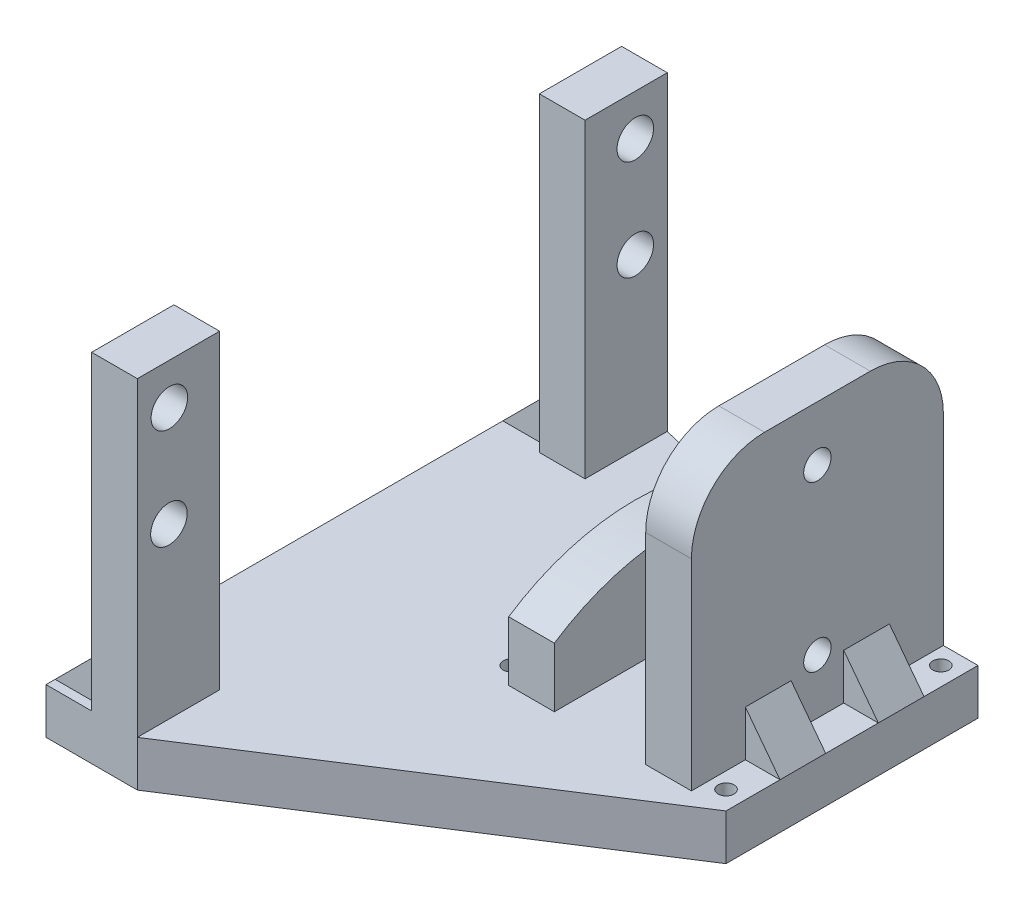
from build123d import *

# Parameters (mm, degrees)
SKETCH1_W            = 27.578431842
SKETCH1_H            = 27.578431842
SKETCH1_R            = 0.875
BOSS_EXTRUDE1_DEPTH  = 5
SKETCH2_W            = 5
SKETCH2_H            = 27.578431842
BOSS_EXTRUDE2_DEPTH  = 30
CUT_EXTRUDE2_DEPTH   = 10
SKETCH5_R            = 1.5
CUT_EXTRUDE3_DEPTH   = 24
FILLET1_R            = 8
FILLET2_R            = 8
SKETCH6_W            = 10
SKETCH6_H            = 10
CUT_EXTRUDE5_DEPTH   = 7
SKETCH7_R            = 3
CUT_EXTRUDE6_DEPTH   = 7
SKETCH8_W            = 3.789215921
SKETCH8_H            = 5
BOSS_EXTRUDE3_DEPTH  = 5
CUT_EXTRUDE7_DEPTH   = 25
SKETCH10_W           = 27.578431842
SKETCH10_H           = 5
BOSS_EXTRUDE4_DEPTH  = 11.61
BOSS_EXTRUDE5_DEPTH  = 5
BOSS_EXTRUDE9_DEPTH  = 5
SKETCH18_W           = 5
SKETCH18_H           = 7
BOSS_EXTRUDE10_DEPTH = 5
CUT_EXTRUDE9_DEPTH   = 59
SKETCH20_R           = 2
CUT_EXTRUDE10_DEPTH  = 10
BOSS_EXTRUDE11_DEPTH = 5


with BuildPart() as part:
    # Sketch1 → Boss-Extrude1 (new body)
    with BuildSketch(Plane(origin=(0, 0, 0), x_dir=(1, 0, 0), z_dir=(0, 1, 0))):
        with Locations((13.789215921, 13.789215921)):
            Rectangle(SKETCH1_W, SKETCH1_H)
        with Locations((2.032931996, 2.032931996)):
            Circle(SKETCH1_R, mode=Mode.SUBTRACT)
        with Locations((25.545499846, 25.545499846)):
            Circle(SKETCH1_R, mode=Mode.SUBTRACT)
        with Locations((2.032931996, 25.545499846)):
            Circle(SKETCH1_R, mode=Mode.SUBTRACT)
        with Locations((25.545513651, 2.032918191)):
            Circle(SKETCH1_R, mode=Mode.SUBTRACT)
    extrude(amount=BOSS_EXTRUDE1_DEPTH)

    # Sketch2 → Boss-Extrude2 (add)
    with BuildSketch(Plane(origin=(0, 5, 0), x_dir=(1, 0, 0), z_dir=(0, 1, 0))):
        with Locations((21.289215921, 13.789215921)):
            Rectangle(SKETCH2_W, SKETCH2_H)
        with Locations((6.289215921, 13.789215921)):
            Rectangle(SKETCH2_W, SKETCH2_H)
    extrude(amount=BOSS_EXTRUDE2_DEPTH)

    # Sketch4 → Cut-Extrude2 (cut)
    with BuildSketch(Plane.ZY.offset(-3.789215921)):
        with BuildLine():
            Line((-27.578431842, 11.509370995), (-27.578431842, 35))
            Line((-27.578431842, 35), (0, 35))
            Line((0, 35), (0, 11.509370995))
            ThreePointArc((0, 11.509370995), (-13.789215921, 15.656133254), (-27.578431842, 11.509370995))
        make_face()
    extrude(amount=-CUT_EXTRUDE2_DEPTH, mode=Mode.SUBTRACT)

    # Sketch5 → Cut-Extrude3 (cut)
    with BuildSketch(Plane(origin=(23.789215921, 0, 0), x_dir=(0, 0, -1), z_dir=(1, 0, 0))):
        with Locations((13.789215921, 29)):
            Circle(SKETCH5_R)
        with Locations((13.789215921, 11)):
            Circle(SKETCH5_R)
    extrude(amount=-CUT_EXTRUDE3_DEPTH, mode=Mode.SUBTRACT)

    # Fillet1
    fillet1_edges = [part.edges().sort_by_distance(p)[0] for p in [
        (21.289215921, 35, 0),
    ]]
    fillet(fillet1_edges, radius=FILLET1_R)

    # Fillet2
    fillet2_edges = [part.edges().sort_by_distance(p)[0] for p in [
        (21.289215921, 35, -27.578431842),
    ]]
    fillet(fillet2_edges, radius=FILLET2_R)

    # Sketch6 → Cut-Extrude5 (cut)
    with BuildSketch(Plane(origin=(0, 5, 0), x_dir=(1, 0, 0), z_dir=(0, 1, 0))):
        with Locations((13.789215921, 22.578431842)):
            Rectangle(SKETCH6_W, SKETCH6_H)
    extrude(amount=-CUT_EXTRUDE5_DEPTH, mode=Mode.SUBTRACT)

    # Sketch7 → Cut-Extrude6 (cut)
    with BuildSketch(Plane.XZ):
        with Locations((13.789215921, -13.789215921)):
            Circle(SKETCH7_R)
    extrude(amount=-CUT_EXTRUDE6_DEPTH, mode=Mode.SUBTRACT)

    # Sketch8 → Boss-Extrude3 (add)
    with BuildSketch(Plane(origin=(0, 5, 0), x_dir=(1, 0, 0), z_dir=(0, 1, 0))):
        with Locations((1.894607961, 19.170499846)):
            Rectangle(SKETCH8_W, SKETCH8_H)
        with Locations((25.683823882, 19.170499846)):
            Rectangle(SKETCH8_W, SKETCH8_H)
        with Locations((25.683823882, 8.407918191)):
            Rectangle(SKETCH8_W, SKETCH8_H)
        with Locations((1.894607961, 8.407918191)):
            Rectangle(SKETCH8_W, SKETCH8_H)
    extrude(amount=BOSS_EXTRUDE3_DEPTH)

    # Sketch9 → Cut-Extrude7 (cut)
    with BuildSketch(Plane.XY.offset(-5.907918191)):
        Polygon((0, 5), (3.789215921, 10), (0, 10), align=None)
        Polygon((23.789215921, 10), (27.578431842, 5), (27.578431842, 10), align=None)
    extrude(amount=-CUT_EXTRUDE7_DEPTH, mode=Mode.SUBTRACT)

    # Sketch10 → Boss-Extrude4 (add)
    with BuildSketch(Plane.ZY):
        with Locations((-13.789215921, 2.5)):
            Rectangle(SKETCH10_W, SKETCH10_H)
    extrude(amount=BOSS_EXTRUDE4_DEPTH)

    # Sketch11 → Boss-Extrude5 (add)
    with BuildSketch(Plane.ZY.offset(11.61)):
        Polygon((-32.758431842, 9.017116473), (-32.758431842, 0), (-27.578431842, 0), (0, 0), (25.24, 0), (25.24, 9.017116473), (25.24, 39), (16.24, 39), (16.24, 5), (0, 5), (-23.758431842, 5), (-23.758431842, 39), (-32.758431842, 39), align=None)
    extrude(amount=BOSS_EXTRUDE5_DEPTH)

    # Sketch17 → Boss-Extrude9 (add)
    with BuildSketch(Plane.ZY.offset(16.61)):
        Polygon((-23.758431842, 5), (-32.758431842, 5), (-32.758431842, 0), (25.24, 0), (25.24, 5), align=None)
    extrude(amount=BOSS_EXTRUDE9_DEPTH)

    # Sketch18 → Boss-Extrude10 (add)
    with BuildSketch(Plane(origin=(0, 5, 0), x_dir=(1, 0, 0), z_dir=(0, 1, 0))):
        with Locations((-19.11, 28.258431842)):
            Rectangle(SKETCH18_W, SKETCH18_H)
        with Locations((-19.11, -20.74)):
            Rectangle(SKETCH18_W, SKETCH18_H)
    extrude(amount=BOSS_EXTRUDE10_DEPTH)

    # Sketch19 → Cut-Extrude9 (cut)
    with BuildSketch(Plane.XY.offset(24.24)):
        Polygon((-21.61, 5), (-21.61, 10), (-16.61, 10), align=None)
    extrude(amount=-CUT_EXTRUDE9_DEPTH, mode=Mode.SUBTRACT)

    # Sketch20 → Cut-Extrude10 (cut)
    with BuildSketch(Plane(origin=(-11.61, 0, 0), x_dir=(0, 0, -1), z_dir=(1, 0, 0))):
        with Locations((-21.738681897, 34.501289775)):
            Circle(SKETCH20_R)
        with Locations((-21.785282729, 23.501291949)):
            Circle(SKETCH20_R)
        with Locations((29.260801868, 23.498896595)):
            Circle(SKETCH20_R)
        with Locations((29.261318047, 34.498896583)):
            Circle(SKETCH20_R)
    extrude(amount=-CUT_EXTRUDE10_DEPTH, mode=Mode.SUBTRACT)

    # Sketch21 → Boss-Extrude11 (add)
    with BuildSketch(Plane(origin=(0, 5, 0), x_dir=(1, 0, 0), z_dir=(0, 1, 0))):
        Polygon((-11.61, -25.24), (27.578431842, 0), (-11.61, 0), align=None)
        Polygon((-11.61, 32.758431842), (8.789215921, 27.578431842), (-11.61, 27.578431842), align=None)
    extrude(amount=-BOSS_EXTRUDE11_DEPTH)


solid = part.part
